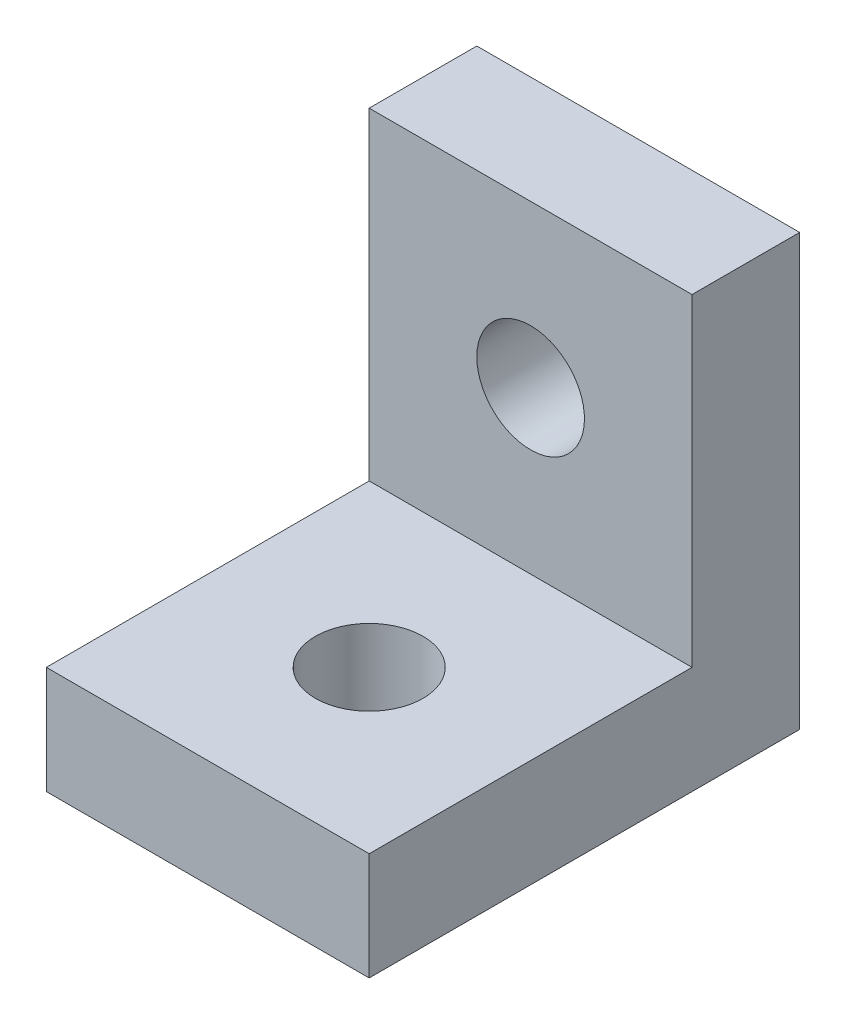
from build123d import *

# Parameters (mm, degrees)
BOSS_EXTRUDE1_DEPTH = 15
CUT_EXTRUDE1_REACH  = 42
SKETCH2_R           = 5
CUT_EXTRUDE2_REACH  = 12
SKETCH3_R           = 5


with BuildPart() as part:
    # Sketch1 → Boss-Extrude1 (new body, symmetric)
    with BuildSketch(Plane(origin=(0, 0, 0), x_dir=(0, 0, -1), z_dir=(1, 0, 0))):
        Polygon((0, 40), (0, 0), (-40, 0), (-40, 10), (-10, 10), (-10, 40), align=None)
    extrude(amount=BOSS_EXTRUDE1_DEPTH, both=True)

    # Sketch2 → Cut-Extrude1 (cut, up to next)
    with BuildSketch(Plane(origin=(0, 0, 0), x_dir=(-1, 0, 0), z_dir=(0, 0, -1)), mode=Mode.PRIVATE) as cut_extrude1_sk1:
        with Locations((0, 25)):
            Circle(SKETCH2_R)
    cut_extrude1_tool1 = extrude(cut_extrude1_sk1.sketch, amount=-CUT_EXTRUDE1_REACH, mode=Mode.PRIVATE) & part.part
    add(cut_extrude1_tool1.solids().sort_by_distance((0, 25, 0))[0], mode=Mode.SUBTRACT)

    # Sketch3 → Cut-Extrude2 (cut, up to next)
    with BuildSketch(Plane(origin=(0, 10, 0), x_dir=(1, 0, 0), z_dir=(0, 1, 0)), mode=Mode.PRIVATE) as cut_extrude2_sk1:
        with Locations((0, -25)):
            Circle(SKETCH3_R)
    cut_extrude2_tool1 = extrude(cut_extrude2_sk1.sketch, amount=-CUT_EXTRUDE2_REACH, mode=Mode.PRIVATE) & part.part
    add(cut_extrude2_tool1.solids().sort_by_distance((0, 10, 25))[0], mode=Mode.SUBTRACT)


solid = part.part
